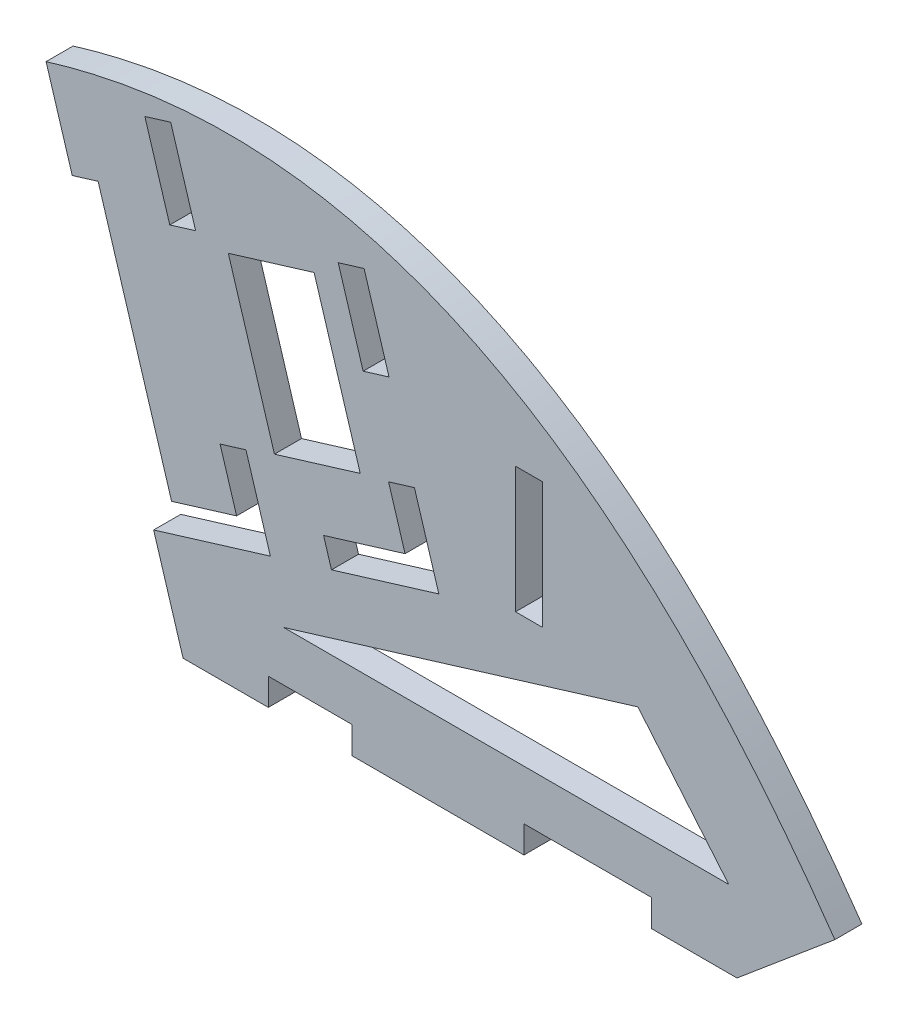
from build123d import *

# Parameters (mm, degrees)
BOSS_EXTRUDE1_DEPTH = 3.175
SKETCH3_W           = 3.175
SKETCH3_H           = 14.8
CUT_EXTRUDE1_DEPTH  = 4.1750001
SKETCH4_W           = 9.8
SKETCH4_H           = 3.175
SKETCH4_W_2         = 15
CUT_EXTRUDE2_DEPTH  = 3.175
CUT_EXTRUDE3_DEPTH  = 4.1750001


with BuildPart() as part:
    # Sketch1 → Boss-Extrude1 (new body)
    with BuildSketch(Plane.XY):
        with BuildLine():
            Line((0, 0), (65, 0))
            Line((65, 0), (76.490666647, 9.641814145))
            add(Edge.make_bspline(
                [(76.490666647, 9.641814145), (35.667607653, 68.4177286), (-16.08044376, 52.596761578)],
                knots=[0, 0, 0, 1, 1, 1], degree=2))
            Line((-16.08044376, 52.596761578), (0, 0))
        make_face()
    extrude(amount=BOSS_EXTRUDE1_DEPTH)

    # Sketch3 → Cut-Extrude1 (cut, through all)
    with BuildSketch(Plane(origin=(0, 0, 0), x_dir=(-1, 0, 0), z_dir=(0, 0, -1))):
        with Locations((-40.601722956, 31.627041635)):
            Rectangle(SKETCH3_W, SKETCH3_H)
        Polygon((-24.165936956, 40.667408524), (-21.242219909, 50.230456083), (-18.205952308, 49.302175921), (-21.129669356, 39.739128361), align=None)
        Polygon((-24.111860744, 29.984819851), (-27.148128344, 30.913100013), (-30.01337105, 21.541313405), (-26.97710345, 20.613033242), align=None)
        Polygon((-26.048823288, 23.649300842), (-26.97710345, 20.613033242), (-17.414055891, 17.689316195), (-16.485775728, 20.725583795), align=None)
        Polygon((-1.470619079, 44.185671088), (1.453097968, 53.748718648), (4.489365568, 52.820438485), (1.565648521, 43.257390926), align=None)
        Polygon((-10.241770221, 15.496528409), (-7.205502621, 14.568248247), (-6.277222458, 17.604515847), (-4.340259914, 23.940034855), (-7.376527515, 24.868315018), align=None)
        Polygon((-7.205502621, 14.568248247), (3.457295408, 11.308303739), (4.385575571, 14.344571339), (-6.277222458, 17.604515847), align=None)
    extrude(amount=-CUT_EXTRUDE1_DEPTH, mode=Mode.SUBTRACT)

    # Sketch4 → Cut-Extrude2 (cut)
    with BuildSketch(Plane(origin=(0, 0, 0), x_dir=(-1, 0, 0), z_dir=(0, 0, -1))):
        with Locations((-14.9, 1.5875)):
            Rectangle(SKETCH4_W, SKETCH4_H)
        with Locations((-47.5, 1.5875)):
            Rectangle(SKETCH4_W_2, SKETCH4_H)
        Polygon((13.01054086, 42.55556164), (9.97427326, 43.483841803), (1.349307971, 15.272851502), (4.385575571, 14.344571339), align=None)
    extrude(amount=-CUT_EXTRUDE2_DEPTH, mode=Mode.SUBTRACT)

    # Sketch5 → Cut-Extrude3 (cut, through all)
    with BuildSketch(Plane.XY.offset(3.175)):
        Polygon((11.804307663, 9.030936103), (53.371240129, 21.739222692), (64.034758718, 9.030936103), align=None)
        Polygon((5.306009056, 43.811965436), (10.721102585, 26.099992585), (20.789996423, 29.178362359), (15.374902893, 46.890335211), align=None)
    extrude(amount=-CUT_EXTRUDE3_DEPTH, mode=Mode.SUBTRACT)


solid = part.part
